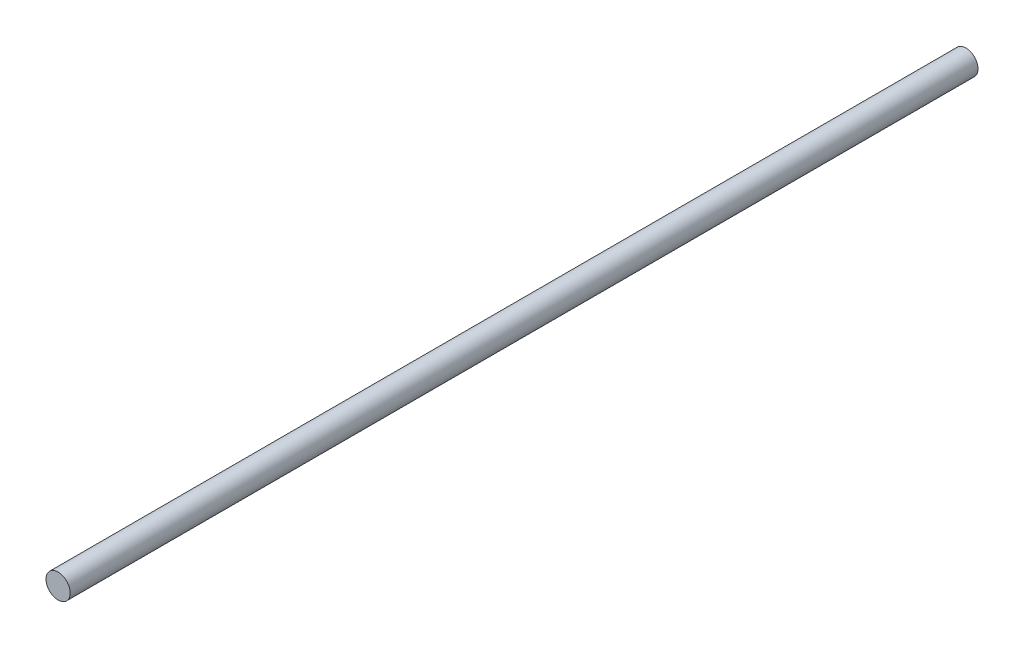
from build123d import *

# Parameters (mm, degrees)
SKETCH1_R           = 2
BOSS_EXTRUDE1_DEPTH = 75


with BuildPart() as part:
    # Sketch1 → Boss-Extrude1 (new body, symmetric)
    with BuildSketch(Plane.XY):
        Circle(SKETCH1_R)
    extrude(amount=BOSS_EXTRUDE1_DEPTH, both=True)


solid = part.part
